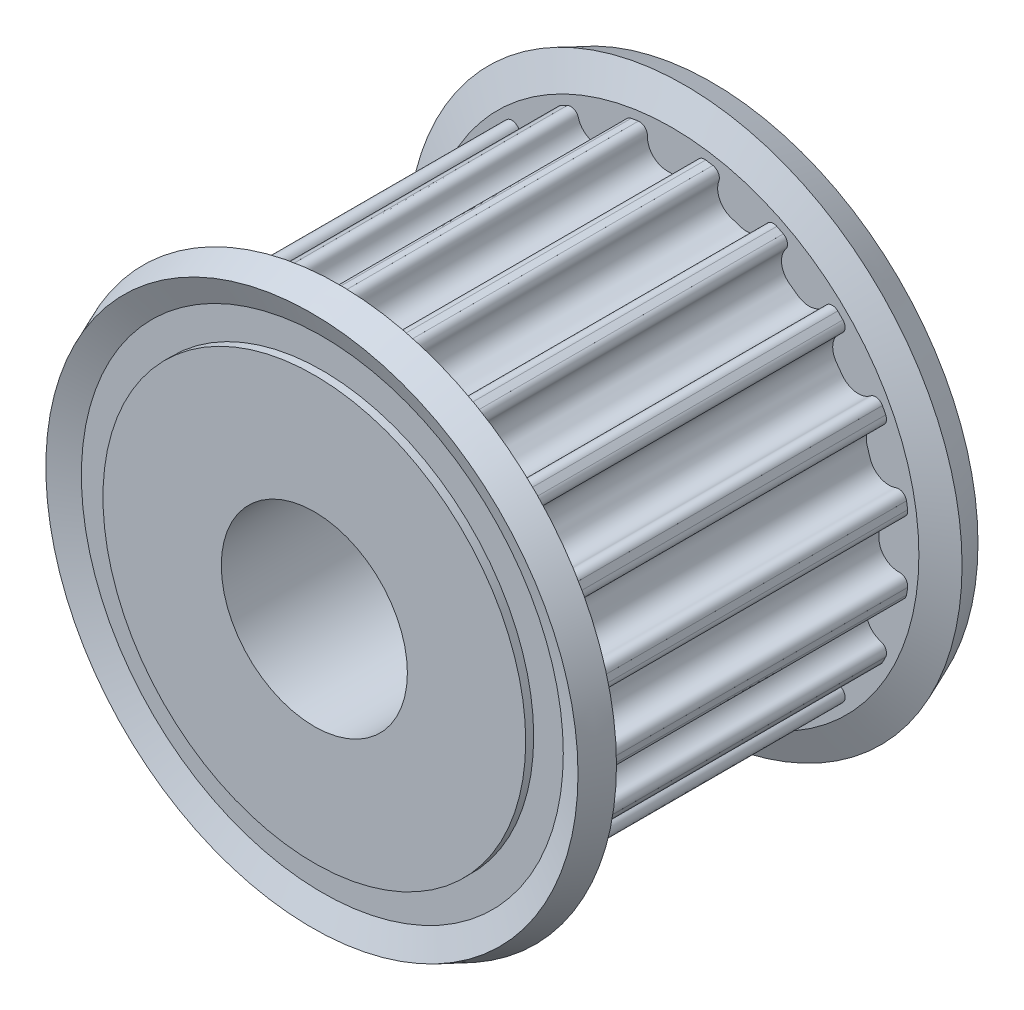
from build123d import *

# Parameters (mm, degrees)
TOOTHEXTRUDECUTGEARBELT01_DEPTH = 10.32699981
PATTERNGEARBELT01_COUNT         = 20
BOREREVOLVESKETCH_W             = 25.790659426
BOREREVOLVESKETCH_H             = 6


with BuildPart() as part:
    # SketchRevolveGearBelt01 → GearBelt01 (revolve)
    with BuildSketch(Plane(origin=(0, 0, 0), x_dir=(0, 0, -1), z_dir=(1, 0, 0))):
        Polygon((12.73999977, 0), (12.73999977, 13.629487395), (12.224379778, 13.629487395), (12.224379778, 15.538075019), (12.895329713, 17.157891451), (11.142379192, 17.883987331), (10.326999806, 15.915487361), (10.326999806, 15.34398737), (-10.326999806, 15.34398737), (-10.326999806, 15.915487361), (-11.142379192, 17.883987331), (-12.895329713, 17.157891451), (-12.224379778, 15.538075019), (-12.224379778, 13.629487395), (-12.73999977, 13.629487395), (-12.73999977, 0), align=None)
    revolve(axis=Axis((0, 0, 0), (0, 0, -1)))

    # SketchToothGearBelt01 → ToothExtrudeCutGearBelt01 (cut, symmetric)
    with BuildSketch(Plane.XY):
        with BuildLine():
            Line((15.755513144, 2.250898375), (15.189205, 2.169993229))
            add(Edge.make_bspline(
                [(15.189205, -2.169993229), (15.193305534, -2.141313845), (15.195757164, -2.097767751), (15.191587416, -2.039923228), (15.184765217, -1.996965665), (15.174297611, -1.954748066), (15.160261262, -1.913579187), (15.14275879, -1.873760103), (15.121918204, -1.835582022), (15.097891913, -1.79932415), (15.070855629, -1.76525165), (15.041007075, -1.733613699), (15.008564541, -1.704641692), (14.973765287, -1.678547436), (14.936863807, -1.655522038), (14.898129981, -1.635732867), (14.85784704, -1.619328456), (14.81630973, -1.606414559), (14.773821272, -1.597138675), (14.730694457, -1.591370625), (14.673606872, -1.58942772), (14.597833368, -1.590802706), (14.50329241, -1.587292017), (14.404301405, -1.575300386), (14.30654119, -1.555720458), (14.210619671, -1.528503959), (14.117125097, -1.493863505), (14.026633028, -1.452000056), (13.939699952, -1.403174359), (13.856860629, -1.347685871), (13.778624594, -1.285876137), (13.705473083, -1.218125284), (13.637856039, -1.144850065), (13.576189416, -1.066501192), (13.520852365, -0.98356059), (13.472185868, -0.896538423), (13.430487022, -0.805969981), (13.396020714, -0.71241229), (13.368967603, -0.616441044), (13.34961107, -0.518645741), (13.337633617, -0.419630986), (13.334152945, -0.299855766), (13.335612406, -0.160003622), (13.335055896, 0), (13.335612406, 0.160003622), (13.334152945, 0.299855766), (13.337633617, 0.419630986), (13.34961107, 0.518645741), (13.368967603, 0.616441044), (13.396020714, 0.71241229), (13.430487022, 0.805969981), (13.472185868, 0.896538423), (13.520852365, 0.98356059), (13.576189416, 1.066501192), (13.637856039, 1.144850065), (13.705473083, 1.218125284), (13.778624594, 1.285876137), (13.856860629, 1.347685871), (13.939699952, 1.403174359), (14.026633028, 1.452000056), (14.117125097, 1.493863505), (14.210619671, 1.528503959), (14.30654119, 1.555720458), (14.404301405, 1.575300386), (14.50329241, 1.587292017), (14.597833368, 1.590802706), (14.673606872, 1.58942772), (14.730694457, 1.591370625), (14.773821272, 1.597138675), (14.81630973, 1.606414559), (14.85784704, 1.619328456), (14.898129981, 1.635732867), (14.936863807, 1.655522038), (14.973765287, 1.678547436), (15.008564541, 1.704641692), (15.041007075, 1.733613699), (15.070855629, 1.76525165), (15.097891913, 1.79932415), (15.121918204, 1.835582022), (15.14275879, 1.873760103), (15.160261262, 1.913579187), (15.174297611, 1.954748066), (15.184765217, 1.996965665), (15.191587416, 2.039923228), (15.195757164, 2.097767751), (15.193305534, 2.141313845), (15.189205, 2.169993229)],
                knots=[0, 0, 0, 0, 0.013304592, 0.019956888, 0.026609185, 0.033261481, 0.039913777, 0.046566073, 0.053218369, 0.059870665, 0.066522961, 0.073175258, 0.079827554, 0.08647985, 0.093132146, 0.099784442, 0.106436738, 0.113089034, 0.11974133, 0.126393627, 0.133045923, 0.145957551, 0.161209637, 0.176461722, 0.191713808, 0.206965894, 0.222217979, 0.237470065, 0.252722151, 0.267974236, 0.283226322, 0.298478408, 0.313730493, 0.328982579, 0.344234665, 0.35948675, 0.374738836, 0.389990922, 0.405243007, 0.420495093, 0.435747179, 0.450999264, 0.475499632, 0.5, 0.524500368, 0.549000736, 0.564252821, 0.579504907, 0.594756993, 0.610009078, 0.625261164, 0.64051325, 0.655765335, 0.671017421, 0.686269507, 0.701521592, 0.716773678, 0.732025764, 0.747277849, 0.762529935, 0.777782021, 0.793034106, 0.808286192, 0.823538278, 0.838790363, 0.854042449, 0.866954077, 0.873606373, 0.88025867, 0.886910966, 0.893563262, 0.900215558, 0.906867854, 0.91352015, 0.920172446, 0.926824742, 0.933477039, 0.940129335, 0.946781631, 0.953433927, 0.960086223, 0.966738519, 0.973390815, 0.980043112, 0.986695408, 1, 1, 1, 1], degree=3))
            Line((15.189205, -2.169993229), (15.755513144, -2.250898375))
            ThreePointArc((15.755513144, -2.250898375), (15.915487361, 0), (15.755513144, 2.250898375))
        make_face()
    toothextrudecutgearbelt01 = extrude(amount=TOOTHEXTRUDECUTGEARBELT01_DEPTH, both=True, mode=Mode.SUBTRACT)

    # PatternGearBelt01: ToothExtrudeCutGearBelt01 ×20 about axis
    patterngearbelt01_axis = Axis((0, 0, 50), (0, 0, -1))
    for i in range(1, PATTERNGEARBELT01_COUNT):
        add(toothextrudecutgearbelt01.rotate(patterngearbelt01_axis, i * 360 / PATTERNGEARBELT01_COUNT), mode=Mode.SUBTRACT)

    # BoreRevolveSketch → BoreRevolveCut (revolve, cut)
    with BuildSketch(Plane(origin=(0, 0, 0), x_dir=(0, 0, -1), z_dir=(1, 0, 0))):
        with Locations((0, 3)):
            Rectangle(BOREREVOLVESKETCH_W, BOREREVOLVESKETCH_H)
    revolve(axis=Axis((0, 0, 0), (0, 0, -1)), mode=Mode.SUBTRACT)


solid = part.part
